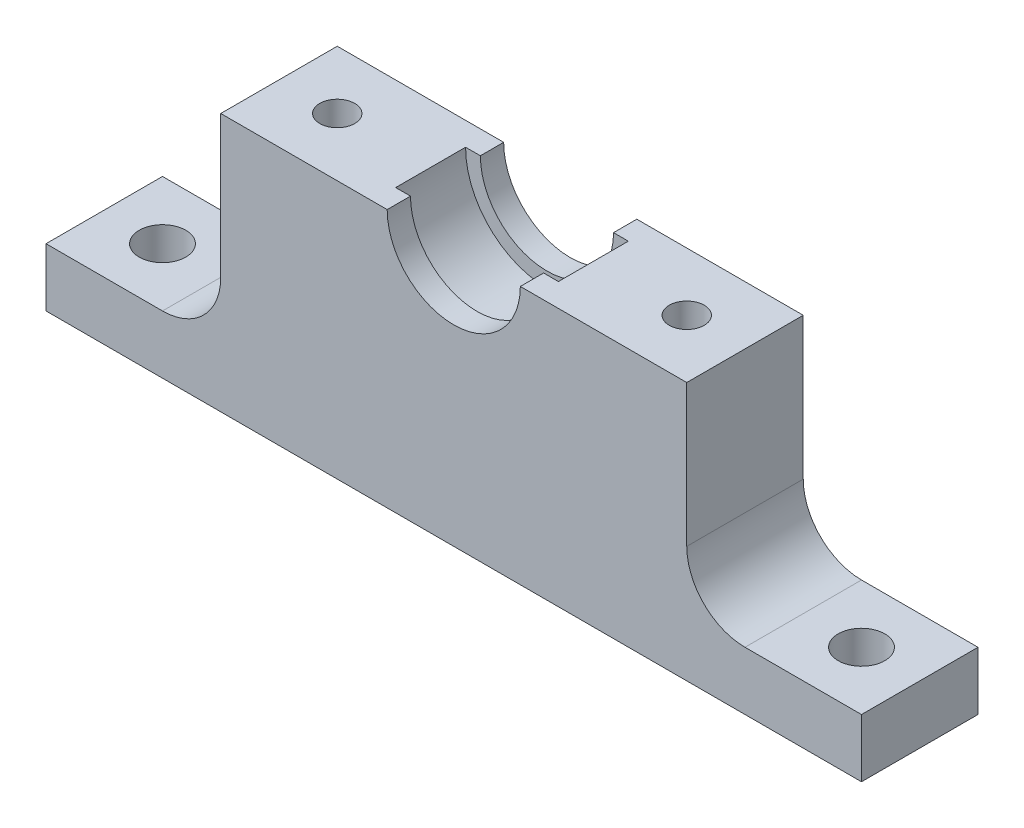
from build123d import *

# Parameters (mm, degrees)
SKETCH1_W           = 40
SKETCH1_H           = 10
BOSS_EXTRUDE1_DEPTH = 22.1798
CUT_EXTRUDE1_DEPTH  = 3
CUT_EXTRUDE2_DEPTH  = 5
SKETCH4_R           = 1.5
CUT_EXTRUDE3_DEPTH  = 7
SKETCH5_W           = 15
SKETCH5_H           = 10
SKETCH5_R           = 2
BOSS_EXTRUDE2_DEPTH = 5
FILLET1_R           = 5


with BuildPart() as part:
    # Sketch1 → Boss-Extrude1 (new body)
    with BuildSketch(Plane(origin=(0, 0, 0), x_dir=(1, 0, 0), z_dir=(0, 1, 0))):
        Rectangle(SKETCH1_W, SKETCH1_H)
    extrude(amount=BOSS_EXTRUDE1_DEPTH)

    # Sketch2 → Cut-Extrude1 (cut, symmetric)
    with BuildSketch(Plane(origin=(0, 0, 0), x_dir=(-1, 0, 0), z_dir=(0, 0, -1))):
        with BuildLine():
            Line((-6.985, 22.1798), (6.985, 22.1798))
            ThreePointArc((6.985, 22.1798), (0, 15.1948), (-6.985, 22.1798))
        make_face()
    extrude(amount=CUT_EXTRUDE1_DEPTH, both=True, mode=Mode.SUBTRACT)

    # Sketch3 → Cut-Extrude2 (cut, symmetric)
    with BuildSketch(Plane(origin=(0, 0, 0), x_dir=(-1, 0, 0), z_dir=(0, 0, -1))):
        with BuildLine():
            Line((-5.715, 22.1798), (5.715, 22.1798))
            ThreePointArc((5.715, 22.1798), (0, 16.4648), (-5.715, 22.1798))
        make_face()
    extrude(amount=CUT_EXTRUDE2_DEPTH, both=True, mode=Mode.SUBTRACT)

    # Sketch4 → Cut-Extrude3 (cut)
    with BuildSketch(Plane(origin=(0, 22.1798, 0), x_dir=(1, 0, 0), z_dir=(0, 1, 0))):
        with Locations((15, 0)):
            Circle(SKETCH4_R)
        with Locations((-15, 0)):
            Circle(SKETCH4_R)
    extrude(amount=-CUT_EXTRUDE3_DEPTH, mode=Mode.SUBTRACT)

    # Sketch5 → Boss-Extrude2 (add)
    with BuildSketch(Plane.XZ):
        with Locations((-27.5, 0)):
            Rectangle(SKETCH5_W, SKETCH5_H)
        with Locations((-30, 0)):
            Circle(SKETCH5_R, mode=Mode.SUBTRACT)
        with Locations((27.5, 0)):
            Rectangle(SKETCH5_W, SKETCH5_H)
        with Locations((30, 0)):
            Circle(SKETCH5_R, mode=Mode.SUBTRACT)
    extrude(amount=-BOSS_EXTRUDE2_DEPTH)

    # Fillet1
    fillet1_edges = [part.edges().sort_by_distance(p)[0] for p in [
        (-20, 5, 0),
        (20, 5, 0),
    ]]
    fillet(fillet1_edges, radius=FILLET1_R)


solid = part.part
